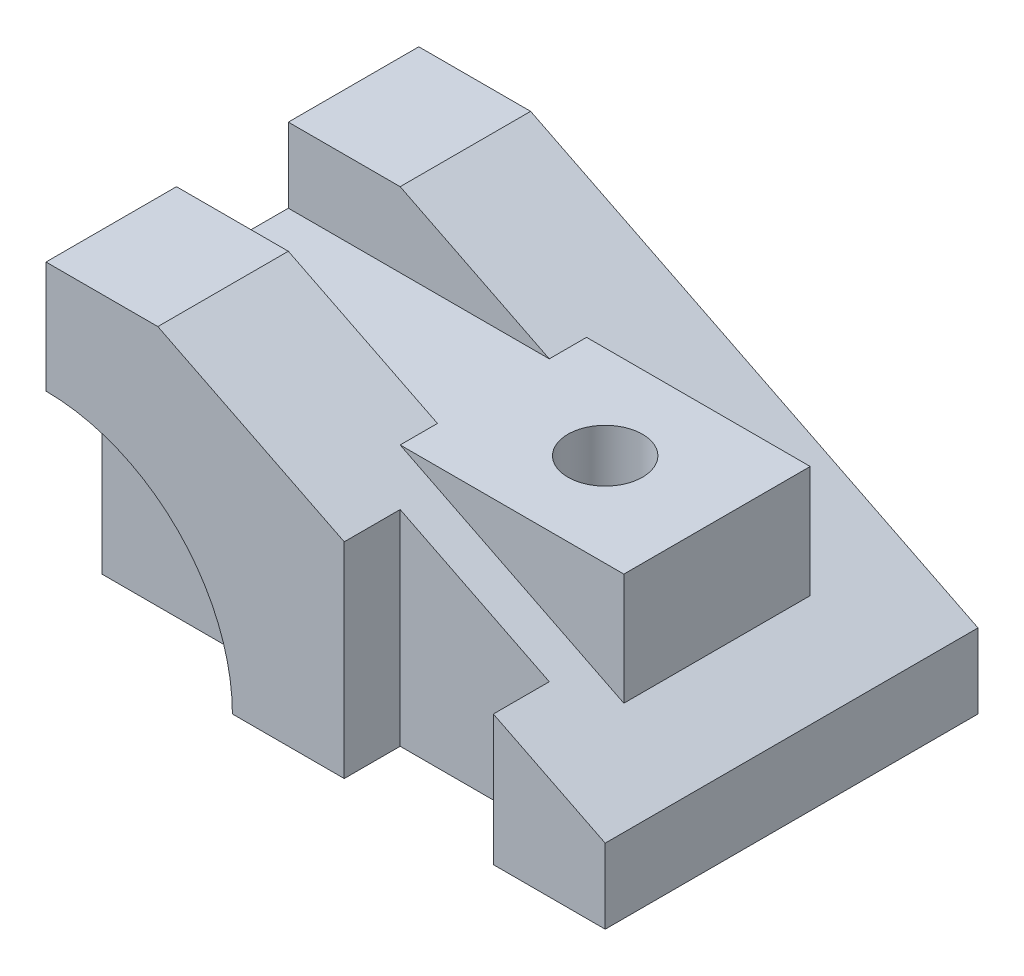
from build123d import *

# Parameters (mm, degrees)
BOSS_EXTRUDE1_DEPTH      = 50
BOSS_EXTRUDE1_DEPTH_BACK = 50
SKETCH2_R                = 50
CUT_EXTRUDE2_DEPTH       = 15
BOSS_EXTRUDE2_DEPTH      = 25
BOSS_EXTRUDE2_DEPTH_BACK = 25
SKETCH5_W                = 104.607091917
SKETCH5_H                = 30
CUT_EXTRUDE3_DEPTH       = 25
SKETCH6_W                = 40
SKETCH6_H                = 15
CUT_EXTRUDE4_DEPTH       = 178.200451467
SKETCH7_R                = 10
CUT_EXTRUDE5_DEPTH       = 170.115345253


with BuildPart() as part:
    # Sketch1 → Boss-Extrude1 (new, two sides: drawn at the far end of the back side and taken through both)
    with BuildSketch(Plane.XY.offset(-BOSS_EXTRUDE1_DEPTH_BACK)):
        Polygon((0, 0), (0, 80), (30, 80), (150, 20), (150, 0), align=None)
    extrude(amount=BOSS_EXTRUDE1_DEPTH + BOSS_EXTRUDE1_DEPTH_BACK)

    # Sketch2 → Cut-Extrude2 (cut)
    with BuildSketch(Plane.XY.offset(50)):
        Circle(SKETCH2_R)
    extrude(amount=-CUT_EXTRUDE2_DEPTH, mode=Mode.SUBTRACT)

    # Sketch4 → Boss-Extrude2 (add, two sides: drawn at the far end of the back side and taken through both)
    with BuildSketch(Plane.XY.offset(-BOSS_EXTRUDE2_DEPTH_BACK)):
        Polygon((70, 60), (130, 60), (130, 30), align=None)
    extrude(amount=BOSS_EXTRUDE2_DEPTH + BOSS_EXTRUDE2_DEPTH_BACK)

    # Sketch5 → Cut-Extrude3 (cut)
    with BuildSketch(Plane(origin=(0, 60, 0), x_dir=(1, 0, 0), z_dir=(0, 1, 0))):
        with Locations((29.093290598, 0)):
            Rectangle(SKETCH5_W, SKETCH5_H)
    extrude(amount=CUT_EXTRUDE3_DEPTH, mode=Mode.SUBTRACT)

    # Sketch6 → Cut-Extrude4 (cut, through all)
    with BuildSketch(Plane.XZ):
        with Locations((100, 42.5)):
            Rectangle(SKETCH6_W, SKETCH6_H)
    extrude(amount=-CUT_EXTRUDE4_DEPTH, mode=Mode.SUBTRACT)

    # Sketch7 → Cut-Extrude5 (cut, through all)
    with BuildSketch(Plane(origin=(0, 60, 0), x_dir=(1, 0, 0), z_dir=(0, 1, 0))):
        with Locations((100, 0)):
            Circle(SKETCH7_R)
    extrude(amount=-CUT_EXTRUDE5_DEPTH, mode=Mode.SUBTRACT)


solid = part.part
